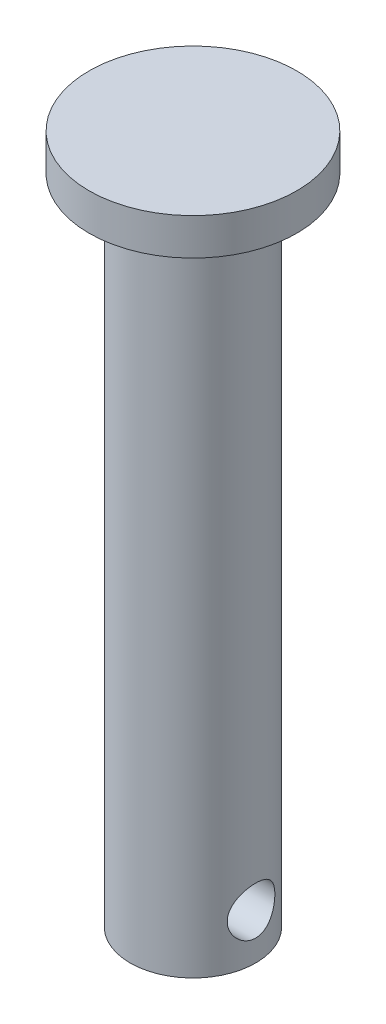
from build123d import *

# Parameters (mm, degrees)
SKETCH1_R               = 2.9
BOSS_EXTRUDE1_DEPTH     = 30.15
SKETCH2_R               = 4.8
BOSS_EXTRUDE2_DEPTH     = 1.7
SKETCH3_R               = 1.1
CUT_EXTRUDE1_DEPTH      = 5.8
CUT_EXTRUDE1_DEPTH_BACK = 5.8


with BuildPart() as part:
    # Sketch1 → Boss-Extrude1 (new body)
    with BuildSketch(Plane(origin=(0, 0, 0), x_dir=(1, 0, 0), z_dir=(0, 1, 0))):
        Circle(SKETCH1_R)
    extrude(amount=-BOSS_EXTRUDE1_DEPTH)

    # Sketch2 → Boss-Extrude2 (add)
    with BuildSketch(Plane(origin=(0, 0, 0), x_dir=(1, 0, 0), z_dir=(0, 1, 0))):
        Circle(SKETCH2_R)
    extrude(amount=BOSS_EXTRUDE2_DEPTH)

    # Sketch3 → Cut-Extrude1 (cut, two sides)
    with BuildSketch(Plane(origin=(0, 0, 0), x_dir=(0, 0, -1), z_dir=(1, 0, 0))) as cut_extrude1_sk:
        with Locations((0, -28.05)):
            Circle(SKETCH3_R)
    extrude(amount=CUT_EXTRUDE1_DEPTH, mode=Mode.SUBTRACT)
    extrude(cut_extrude1_sk.sketch, amount=-CUT_EXTRUDE1_DEPTH_BACK, mode=Mode.SUBTRACT)


solid = part.part
